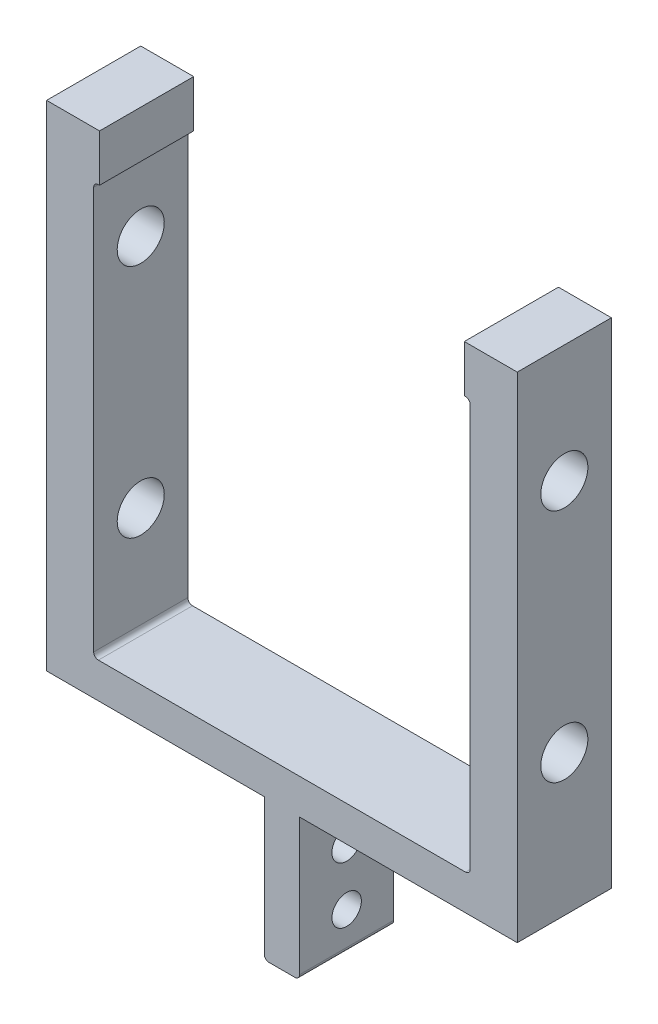
from build123d import *

# Parameters (mm, degrees)
BOSS_EXTRUDE1_DEPTH = 12.7
SKETCH2_R           = 6.35
CUT_EXTRUDE1_DEPTH  = 128
FILLET1_R           = 1.27
HOLE1_D             = 7.94512
HOLE1_DEPTH         = 68.2625
HOLE1_TIP           = 2.386954861


with BuildPart() as part:
    # Sketch1 → Boss-Extrude1 (new body, symmetric)
    with BuildSketch(Plane.XY):
        Polygon((4.7625, 0), (-4.7625, 0), (-4.7625, 38.1), (-63.5, 38.1), (-63.5, 171.45), (-49.2125, 171.45), (-49.2125, 158.75), (-50.8, 158.75), (-50.8, 47.625), (50.8, 47.625), (50.8, 158.75), (49.2125, 158.75), (49.2125, 171.45), (63.5, 171.45), (63.5, 38.1), (4.7625, 38.1), align=None)
    extrude(amount=BOSS_EXTRUDE1_DEPTH, both=True)

    # Sketch2 → Cut-Extrude1 (cut, through all)
    with BuildSketch(Plane.ZY.offset(63.5)):
        with Locations((0, 76.2)):
            Circle(SKETCH2_R)
        with Locations((0, 139.7)):
            Circle(SKETCH2_R)
    extrude(amount=-CUT_EXTRUDE1_DEPTH, mode=Mode.SUBTRACT)

    # Fillet1
    fillet1_edges = [part.edges().sort_by_distance(p)[0] for p in [
        (4.7625, 0, 0),
        (-4.7625, 0, 0),
        (-50.8, 158.75, 0),
        (-50.8, 47.625, 0),
        (50.8, 47.625, 0),
        (50.8, 158.75, 0),
    ]]
    fillet(fillet1_edges, radius=FILLET1_R)

    # Hole1
    with Locations(Plane(origin=(4.7625, 0, 0), x_dir=(0, 0, 1), z_dir=(1, 0, 0))):
        with Locations((0, -25.4), (0, -10.16)):
            Hole(HOLE1_D / 2, depth=HOLE1_DEPTH)
            with Locations((0, 0, -(HOLE1_DEPTH + HOLE1_TIP / 2))):  # 118° drill point
                Cone(0, HOLE1_D / 2, HOLE1_TIP, mode=Mode.SUBTRACT)


solid = part.part
